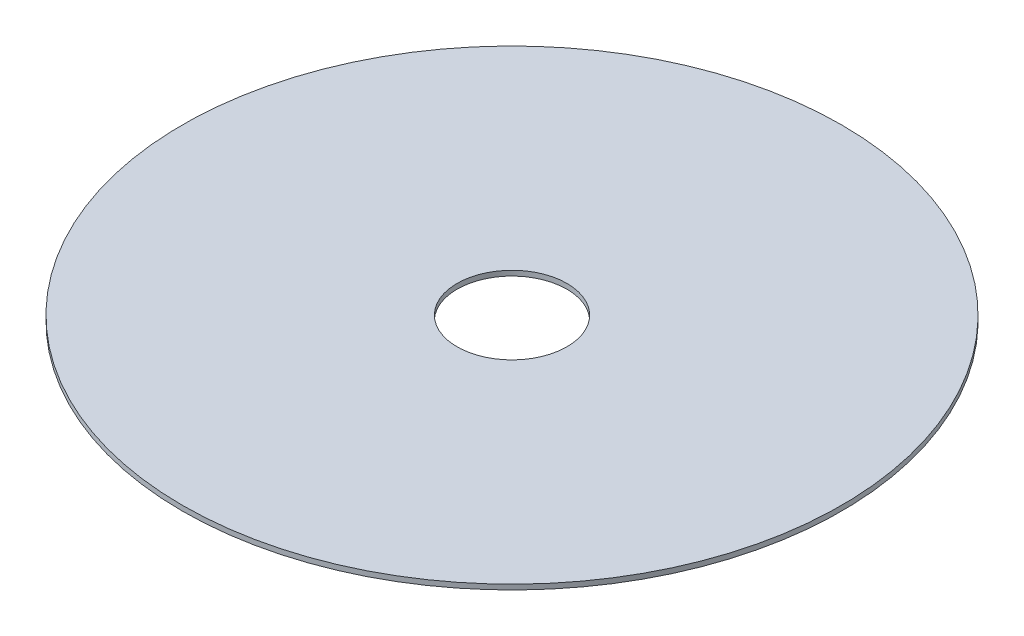
from build123d import *

# Parameters (mm, degrees)
SKETCH1_W = 1250
SKETCH1_H = 23


with BuildPart() as part:
    # Sketch1 → Revolve1 (revolve)
    with BuildSketch(Plane.XY):
        with Locations((875, 0)):
            Rectangle(SKETCH1_W, SKETCH1_H)
    revolve(axis=Axis((0, 0, 0), (0, 1, 0)))


solid = part.part
